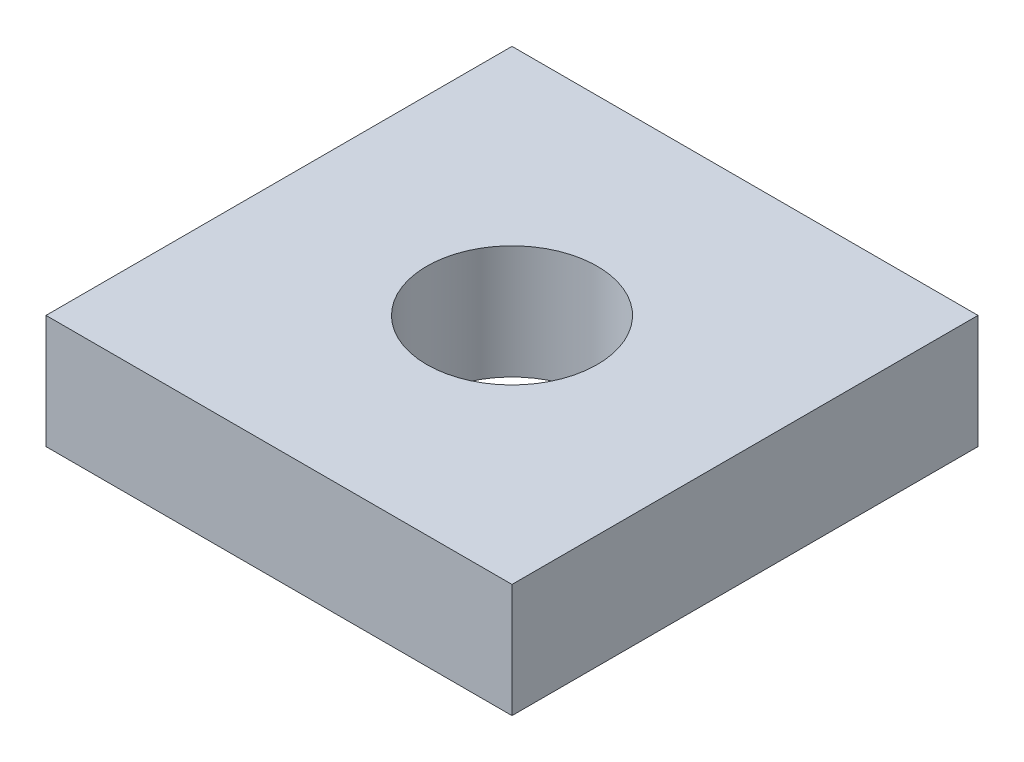
from build123d import *

# Parameters (mm, degrees)
SKETCH_1_W      = 8.2
SKETCH_1_H      = 8.2
SKETCH_1_R      = 1.5
EXTRUDE_1_DEPTH = 2


with BuildPart() as part:
    # Эскиз1 → Бобышка-Вытянуть1 (new body)
    with BuildSketch(Plane(origin=(0, 0, 0), x_dir=(1, 0, 0), z_dir=(0, 1, 0))):
        with Locations((4.1, 4.1)):
            Rectangle(SKETCH_1_W, SKETCH_1_H)
        with Locations((4.1, 4.1)):
            Circle(SKETCH_1_R, mode=Mode.SUBTRACT)
    extrude(amount=EXTRUDE_1_DEPTH)


solid = part.part
